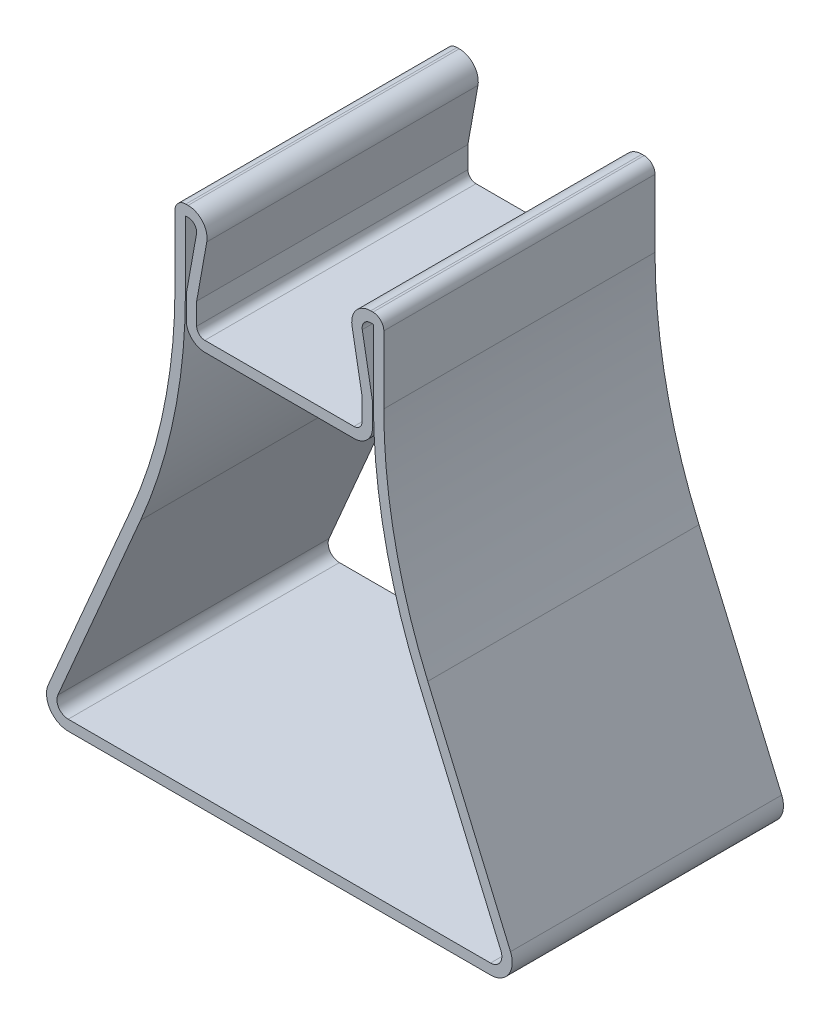
from build123d import *

# Parameters (mm, degrees)
MAIN_BOSS_DEPTH        = 25
FILLET_SHOULDER_R      = 100
FILLET_BASE_R          = 4
FILLET_TOP_R           = 2
FILLET_GROOVE_R        = 1.5
FILLET_TOPS_R          = 3.5
CUT_TO_THICKNESS_DEPTH = 100.840021719
VERSION_NO_DEPTH       = 0.25


with BuildPart() as part:
    # Sketch1 → main_boss (new, symmetric)
    with BuildSketch(Plane.XY):
        Polygon((-15.25, 0), (15.25, 0), (15.25, 5.5), (12.65, 20), (15.25, 20), (19.25, 20), (19.25, -15), (45, -75), (-45, -75), (-19.25, -15), (-19.25, 20), (-15.25, 20), (-12.65, 20), (-15.25, 5.5), align=None)
    extrude(amount=MAIN_BOSS_DEPTH, both=True)

    # fillet shoulder
    fillet_shoulder_edges = [part.edges().sort_by_distance(p)[0] for p in [
        (19.25, -15, 0),
        (-19.25, -15, 0),
    ]]
    fillet(fillet_shoulder_edges, radius=FILLET_SHOULDER_R)

    # fillet base
    fillet_base_edges = [part.edges().sort_by_distance(p)[0] for p in [
        (45, -75, 0),
        (-45, -75, 0),
    ]]
    fillet(fillet_base_edges, radius=FILLET_BASE_R)

    # fillet top
    fillet_top_edges = [part.edges().sort_by_distance(p)[0] for p in [
        (19.25, 20, 0),
        (-19.25, 20, 0),
    ]]
    fillet(fillet_top_edges, radius=FILLET_TOP_R)

    # fillet groove
    fillet_groove_edges = [part.edges().sort_by_distance(p)[0] for p in [
        (-15.25, 0, 0),
        (15.25, 0, 0),
    ]]
    fillet(fillet_groove_edges, radius=FILLET_GROOVE_R)

    # fillet_tops
    fillet_tops_edges = [part.edges().sort_by_distance(p)[0] for p in [
        (12.65, 20, 0),
        (-12.65, 20, 0),
    ]]
    fillet(fillet_tops_edges, radius=FILLET_TOPS_R)

    # Sketch3 → cut_to_thickness (cut, through all)
    with BuildSketch(Plane.XY.offset(25)):
        with BuildLine():
            Line((15.278211108, 16.221137214), (17.17, 5.670776084))
            Line((17.17, 5.670776084), (17.17, 1.5))
            ThreePointArc((17.17, 1.5), (16.168305192, -0.918305192), (13.75, -1.92))
            Line((13.75, -1.92), (-13.75, -1.92))
            ThreePointArc((-13.75, -1.92), (-16.168305192, -0.918305192), (-17.17, 1.5))
            Line((-17.17, 1.5), (-17.17, 5.670776084))
            Line((-17.17, 5.670776084), (-15.278211108, 16.221137214))
            ThreePointArc((-15.278211108, 16.221137214), (-15.621589934, 17.513853243), (-16.833407413, 18.08))
            Line((-16.833407413, 18.08), (-17.25, 18.08))
            ThreePointArc((-17.25, 18.08), (-17.306568542, 18.056568542), (-17.33, 18))
            Line((-17.33, 18), (-17.33, 5.551968899))
            ThreePointArc((-17.33, 5.551968899), (-19.416593138, -14.96576183), (-25.590935524, -34.643379605))
            Line((-25.590935524, -34.643379605), (-40.841934013, -70.179686765))
            ThreePointArc((-40.841934013, -70.179686765), (-40.667281789, -72.144584744), (-38.930524534, -73.08))
            Line((-38.930524534, -73.08), (38.930524534, -73.08))
            ThreePointArc((38.930524534, -73.08), (40.667281789, -72.144584744), (40.841934013, -70.179686765))
            Line((40.841934013, -70.179686765), (25.590935524, -34.643379605))
            ThreePointArc((25.590935524, -34.643379605), (19.416593138, -14.96576183), (17.33, 5.551968899))
            Line((17.33, 5.551968899), (17.33, 18))
            ThreePointArc((17.33, 18), (17.306568542, 18.056568542), (17.25, 18.08))
            Line((17.25, 18.08), (16.833407413, 18.08))
            ThreePointArc((16.833407413, 18.08), (15.621589934, 17.513853243), (15.278211108, 16.221137214))
        make_face()
    extrude(amount=-CUT_TO_THICKNESS_DEPTH, mode=Mode.SUBTRACT)

    # Sketch4 → version_no (cut)
    with BuildSketch(Plane(origin=(0, -73.08, 0), x_dir=(1, 0, 0), z_dir=(0, 1, 0))):
        with BuildLine():
            Line((29.378298124, 17.643202668), (31.271349843, 12.684607132))
            add(Edge.make_bspline(
                [(31.271349843, 12.684607132), (31.280255009, 12.663561278), (31.297627218, 12.622505004), (31.338415918, 12.56939957), (31.390298814, 12.528777015), (31.448000095, 12.494919253), (31.513425416, 12.474035091), (31.582657287, 12.465433561), (31.655592926, 12.465731468), (31.703793377, 12.47699189), (31.728762984, 12.482825203)],
                knots=[0, 0, 0, 0, 0.993570476, 1.93825827, 2.879819244, 3.851437572, 4.841099097, 5.8484807, 6.885433823, 8, 8, 8, 8], degree=3))
            add(Edge.make_bspline(
                [(31.728762984, 12.482825203), (31.751925455, 12.491411622), (31.796762798, 12.508033), (31.857472527, 12.542905125), (31.904453825, 12.590070937), (31.942205733, 12.642215227), (31.965749178, 12.70175494), (31.97843476, 12.764052635), (31.975409882, 12.82961822), (31.9634849, 12.871860613), (31.957319895, 12.893699187)],
                knots=[0, 0, 0, 0, 1.11871001, 2.165571364, 3.138961401, 4.112964469, 5.061298682, 6.015906399, 6.974258505, 8, 8, 8, 8], degree=3))
            Line((31.957319895, 12.893699187), (29.731945149, 18.775552294))
            add(Edge.make_bspline(
                [(29.731945149, 18.775552294), (29.716265161, 18.809146526), (29.685942529, 18.874112491), (29.603239435, 18.946825051), (29.497100364, 18.98912807), (29.418961071, 18.992767461), (29.377136968, 18.994715447)],
                knots=[0, 0, 0, 0, 0.987395857, 1.90946841, 2.881041735, 4, 4, 4, 4], degree=3))
            add(Edge.make_bspline(
                [(29.377136968, 18.994715447), (29.336628067, 18.992728511), (29.260617863, 18.989000259), (29.157421863, 18.946728786), (29.077330249, 18.873869879), (29.049429314, 18.80902813), (29.034962171, 18.775406504)],
                knots=[0, 0, 0, 0, 1.108002112, 2.079036079, 3.003945262, 4, 4, 4, 4], degree=3))
            Line((29.034962171, 18.775406504), (26.798755124, 12.894639724))
            add(Edge.make_bspline(
                [(26.798755124, 12.894639724), (26.792388126, 12.872496512), (26.780161025, 12.829972969), (26.777174788, 12.764055019), (26.789826584, 12.701736983), (26.813452522, 12.642284967), (26.851087259, 12.58954102), (26.899259179, 12.543780495), (26.958970864, 12.507588305), (27.003596167, 12.491304176), (27.02683209, 12.482825203)],
                knots=[0, 0, 0, 0, 1.039577766, 1.996391888, 2.94946763, 3.896279937, 4.868719905, 5.854931054, 6.883085319, 8, 8, 8, 8], degree=3))
            add(Edge.make_bspline(
                [(27.02683209, 12.482825203), (27.052688441, 12.476987941), (27.102674532, 12.465703213), (27.178195801, 12.465482569), (27.249682553, 12.473827151), (27.316693759, 12.495039226), (27.375555447, 12.527956561), (27.426509885, 12.569894855), (27.46688397, 12.622468159), (27.485169846, 12.662949723), (27.494515017, 12.683638211)],
                knots=[0, 0, 0, 0, 1.134111199, 2.192489785, 3.221444196, 4.213470965, 5.186233245, 6.098373757, 7.028155854, 8, 8, 8, 8], degree=3))
            Line((27.494515017, 12.683638211), (29.378298124, 17.643202668))
        make_face()
        with BuildLine():
            add(Edge.make_bspline(
                [(25.287963394, 13.877031131), (25.304898434, 13.891566857), (25.33832151, 13.920254635), (25.373883133, 13.976032125), (25.397974568, 14.03813124), (25.400876288, 14.082491985), (25.402360545, 14.105182927)],
                knots=[0, 0, 0, 0, 1.008922839, 1.991214864, 2.972487386, 4, 4, 4, 4], degree=3))
            add(Edge.make_bspline(
                [(25.402360545, 14.105182927), (25.400763593, 14.127830304), (25.397652054, 14.171956985), (25.37522157, 14.234669995), (25.340341622, 14.290760845), (25.293388947, 14.339885236), (25.237434014, 14.380342144), (25.173307393, 14.410042598), (25.10266226, 14.429108564), (25.052824907, 14.431561747), (25.027157293, 14.432825203)],
                knots=[0, 0, 0, 0, 0.982058384, 1.913465571, 2.858129115, 3.832147666, 4.845908253, 5.838339476, 6.886685086, 8, 8, 8, 8], degree=3))
            add(Edge.make_bspline(
                [(25.027157293, 14.432825203), (25.000580369, 14.430633964), (24.949345791, 14.426409728), (24.876813806, 14.405663876), (24.810892308, 14.376399929), (24.774292204, 14.346900821), (24.75632396, 14.332418699)],
                knots=[0, 0, 0, 0, 1.084590219, 2.090856037, 3.062735851, 4, 4, 4, 4], degree=3))
            Line((24.75632396, 14.332418699), (23.91950676, 13.562026109))
            Line((23.91950676, 13.562026109), (23.91950676, 18.666759658))
            add(Edge.make_bspline(
                [(23.91950676, 18.666759658), (23.917573067, 18.689072784), (23.913780673, 18.732833695), (23.891423521, 18.794854297), (23.858228422, 18.851354206), (23.812512753, 18.899893501), (23.758758956, 18.941679076), (23.69560439, 18.970033814), (23.626553001, 18.989617666), (23.578012536, 18.992971267), (23.552767049, 18.994715447)],
                knots=[0, 0, 0, 0, 0.983861883, 1.929567972, 2.878656923, 3.854386645, 4.852466406, 5.860133368, 6.887073382, 8, 8, 8, 8], degree=3))
            add(Edge.make_bspline(
                [(23.552767049, 18.994715447), (23.527549068, 18.992893943), (23.478636911, 18.989361), (23.409205075, 18.970695613), (23.346408819, 18.94084622), (23.291736304, 18.900422318), (23.246135061, 18.851249001), (23.212469913, 18.795133889), (23.19185419, 18.732284616), (23.18852559, 18.688365199), (23.186811765, 18.665752033)],
                knots=[0, 0, 0, 0, 1.109623447, 2.152197559, 3.139373612, 4.150001298, 5.122835048, 6.069107099, 7.005824623, 8, 8, 8, 8], degree=3))
            Line((23.186811765, 18.665752033), (23.186811765, 12.820302476))
            add(Edge.make_bspline(
                [(23.186811765, 12.820302476), (23.188549187, 12.797939188), (23.191941402, 12.754276204), (23.212452695, 12.691633832), (23.246195019, 12.63561988), (23.291327539, 12.586244736), (23.346859251, 12.547428505), (23.409151692, 12.517411309), (23.47858063, 12.498452598), (23.527543455, 12.495986089), (23.552767049, 12.494715447)],
                knots=[0, 0, 0, 0, 0.986441387, 1.925967889, 2.875077569, 3.850828601, 4.853077154, 5.843213498, 6.888914025, 8, 8, 8, 8], degree=3))
            add(Edge.make_bspline(
                [(23.552767049, 12.494715447), (23.577988176, 12.495988313), (23.626520866, 12.498437674), (23.695591125, 12.517122094), (23.756312728, 12.549215466), (23.789782005, 12.57899304), (23.806425586, 12.593800813)],
                knots=[0, 0, 0, 0, 1.081879838, 2.081847424, 3.046142315, 4, 4, 4, 4], degree=3))
            Line((23.806425586, 12.593800813), (25.287963394, 13.877031131))
        make_face()
        with BuildLine():
            add(Edge.make_bspline(
                [(21.746546108, 18.654326251), (21.744631425, 18.676786603), (21.740854794, 18.721088703), (21.719275855, 18.784410668), (21.683523391, 18.840820267), (21.637661865, 18.890879431), (21.581811122, 18.931690722), (21.518600927, 18.963066761), (21.447485114, 18.981335325), (21.397737728, 18.984933831), (21.372096317, 18.986788618)],
                knots=[0, 0, 0, 0, 0.97382591, 1.920830681, 2.863020957, 3.848433287, 4.844129736, 5.842198414, 6.887799302, 8, 8, 8, 8], degree=3))
            add(Edge.make_bspline(
                [(21.372096317, 18.986788618), (21.346445153, 18.984954218), (21.296678845, 18.981395265), (21.225310306, 18.962746961), (21.161301922, 18.93209265), (21.105233601, 18.890835221), (21.059331684, 18.840832717), (21.023636619, 18.784403009), (21.001822714, 18.720982318), (20.998554649, 18.676485385), (20.996893065, 18.653861789)],
                knots=[0, 0, 0, 0, 1.109035984, 2.151661663, 3.164008816, 4.156872058, 5.139480442, 6.078989761, 7.023299874, 8, 8, 8, 8], degree=3))
            Line((20.996893065, 18.653861789), (20.997646527, 18.33109895))
            add(Edge.make_bspline(
                [(20.997646527, 18.33109895), (20.998911392, 18.307267273), (21.001362118, 18.261092429), (21.023770226, 18.195832911), (21.058519766, 18.138198921), (21.105405241, 18.089247217), (21.161375184, 18.049248383), (21.22543649, 18.019956564), (21.296790636, 18.002682065), (21.346459498, 17.999974671), (21.372096317, 17.998577236)],
                knots=[0, 0, 0, 0, 1.02078656, 1.977815486, 2.928279707, 3.891642941, 4.867917995, 5.866655747, 6.898864241, 8, 8, 8, 8], degree=3))
            add(Edge.make_bspline(
                [(21.372096317, 17.998577236), (21.397723935, 17.99999479), (21.44737497, 18.002741165), (21.518463368, 18.019647116), (21.581750016, 18.049641095), (21.637488982, 18.089204952), (21.684333225, 18.138211276), (21.719152452, 18.195824935), (21.741226168, 18.260847625), (21.744366724, 18.306668201), (21.745978431, 18.330182927)],
                knots=[0, 0, 0, 0, 1.105149421, 2.141120335, 3.126272674, 4.10610627, 5.072980982, 6.026909664, 6.98742698, 8, 8, 8, 8], degree=3))
            Line((21.745978431, 18.330182927), (21.746546108, 18.654326251))
        make_face()
        with BuildLine():
            Line((16.974395685, 17.69414519), (16.974395685, 18.671253335))
            add(Edge.make_bspline(
                [(16.974395685, 18.671253335), (16.976719977, 18.696253363), (16.981146287, 18.743862664), (16.972576515, 18.813388678), (16.946527609, 18.874788658), (16.9058885, 18.926786869), (16.854316422, 18.969139457), (16.793213731, 18.999501539), (16.724471458, 19.020696665), (16.675271936, 19.022721907), (16.649555667, 19.023780488)],
                knots=[0, 0, 0, 0, 1.087299909, 2.070621162, 3.003677159, 3.943551696, 4.907195165, 5.872541018, 6.887991074, 8, 8, 8, 8], degree=3))
            add(Edge.make_bspline(
                [(16.649555667, 19.023780488), (16.62301933, 19.021979197), (16.571933144, 19.018511457), (16.499836787, 18.999962994), (16.435526666, 18.970273058), (16.380615106, 18.929455492), (16.334992502, 18.880322185), (16.301332832, 18.824196812), (16.280715677, 18.761350222), (16.277387276, 18.717430432), (16.275673553, 18.694817073)],
                knots=[0, 0, 0, 0, 1.151181366, 2.21618627, 3.206904126, 4.20349078, 5.162808585, 6.095933722, 7.019637076, 8, 8, 8, 8], degree=3))
            Line((16.275673553, 18.694817073), (16.276344444, 17.702328764))
            Line((16.276344444, 17.702328764), (15.527444863, 17.702328764))
            add(Edge.make_bspline(
                [(15.527444863, 17.702328764), (15.502035194, 17.701759669), (15.4533123, 17.700668432), (15.382288802, 17.688604564), (15.319969701, 17.659661507), (15.265248734, 17.621654263), (15.220793725, 17.573460695), (15.189189519, 17.517204497), (15.168230217, 17.454791041), (15.164959303, 17.410840549), (15.163275179, 17.388211382)],
                knots=[0, 0, 0, 0, 1.128034989, 2.163000553, 3.169143836, 4.150687076, 5.105198403, 6.050662026, 6.99632765, 8, 8, 8, 8], degree=3))
            add(Edge.make_bspline(
                [(15.163275179, 17.388211382), (15.164921042, 17.365575934), (15.168087205, 17.322031871), (15.189158217, 17.260441947), (15.221221141, 17.205426578), (15.26517623, 17.15735673), (15.320242785, 17.119409863), (15.382461316, 17.089789504), (15.452604971, 17.072620681), (15.501396068, 17.069900457), (15.526588187, 17.068495935)],
                knots=[0, 0, 0, 0, 1.006740832, 1.936678581, 2.868061777, 3.825491289, 4.810035357, 5.827409733, 6.878234818, 8, 8, 8, 8], degree=3))
            Line((15.526588187, 17.068495935), (16.19847857, 17.060569106))
            Line((16.19847857, 17.060569106), (16.19847857, 16.076279853))
            add(Edge.make_bspline(
                [(16.19847857, 16.076279853), (16.220242756, 16.032610718), (16.263348922, 15.94611959), (16.349602681, 15.858776037), (16.43087425, 15.807996942), (16.497607576, 15.777819107), (16.571662814, 15.760763001), (16.623049518, 15.758020381), (16.649555667, 15.756605691)],
                knots=[0, 0, 0, 0, 1.490115111, 2.951323312, 3.685756095, 4.423534266, 5.18683178, 6, 6, 6, 6], degree=3))
            add(Edge.make_bspline(
                [(16.649555667, 15.756605691), (16.675183719, 15.757998366), (16.724408274, 15.760673317), (16.794693635, 15.777608447), (16.856231713, 15.807836442), (16.910955268, 15.845858775), (16.956319355, 15.893067315), (16.988249839, 15.948606198), (17.00924071, 16.009708542), (17.012507547, 16.052806558), (17.014189813, 16.075)],
                knots=[0, 0, 0, 0, 1.141910499, 2.19330111, 3.193492141, 4.178566064, 5.149873055, 6.081757497, 7.012195714, 8, 8, 8, 8], degree=3))
            Line((17.014189813, 16.075), (17.014842641, 17.000196702))
            Line((17.014842641, 17.000196702), (18.762274997, 17.000196702))
            Line((18.762274997, 17.000196702), (17.420496581, 12.934618347))
            add(Edge.make_bspline(
                [(17.420496581, 12.934618347), (17.413372067, 12.906178613), (17.399887046, 12.852348915), (17.405337386, 12.770766128), (17.425629117, 12.694678529), (17.468093878, 12.627749064), (17.523176288, 12.569430931), (17.593875944, 12.529157866), (17.6744622, 12.500762319), (17.732616786, 12.496802838), (17.763275179, 12.494715447)],
                knots=[0, 0, 0, 0, 1.068201145, 2.02185239, 2.962018924, 3.925457041, 4.895767801, 5.873036201, 6.878690438, 8, 8, 8, 8], degree=3))
            add(Edge.make_bspline(
                [(17.763275179, 12.494715447), (17.8052636, 12.498890115), (17.884160106, 12.506734342), (17.98867708, 12.555084628), (18.0719567, 12.628093887), (18.101923949, 12.69355839), (18.11734022, 12.727235772)],
                knots=[0, 0, 0, 0, 1.117670421, 2.100109731, 3.022625569, 4, 4, 4, 4], degree=3))
            Line((18.11734022, 12.727235772), (19.594385642, 17.199025422))
            add(Edge.make_bspline(
                [(19.594385642, 17.199025422), (19.60107229, 17.218353302), (19.614236522, 17.25640476), (19.621288786, 17.296043945), (19.624758919, 17.31554878)],
                knots=[0, 0, 0, 0, 1.015881122, 2, 2, 2, 2], degree=3))
            add(Edge.make_bspline(
                [(19.624758919, 17.31554878), (19.623165588, 17.344310691), (19.620103654, 17.399583001), (19.598823907, 17.477483042), (19.563995212, 17.544959299), (19.517271056, 17.601050604), (19.461041858, 17.644947508), (19.397458397, 17.677364641), (19.326544119, 17.697870046), (19.276560033, 17.700149758), (19.250876805, 17.701321138)],
                knots=[0, 0, 0, 0, 1.145314441, 2.200972469, 3.189774196, 4.149024459, 5.086197647, 6.012134926, 6.978579067, 8, 8, 8, 8], degree=3))
            Line((19.250876805, 17.701321138), (16.974395685, 17.69414519))
        make_face()
    extrude(amount=-VERSION_NO_DEPTH, mode=Mode.SUBTRACT)


solid = part.part
